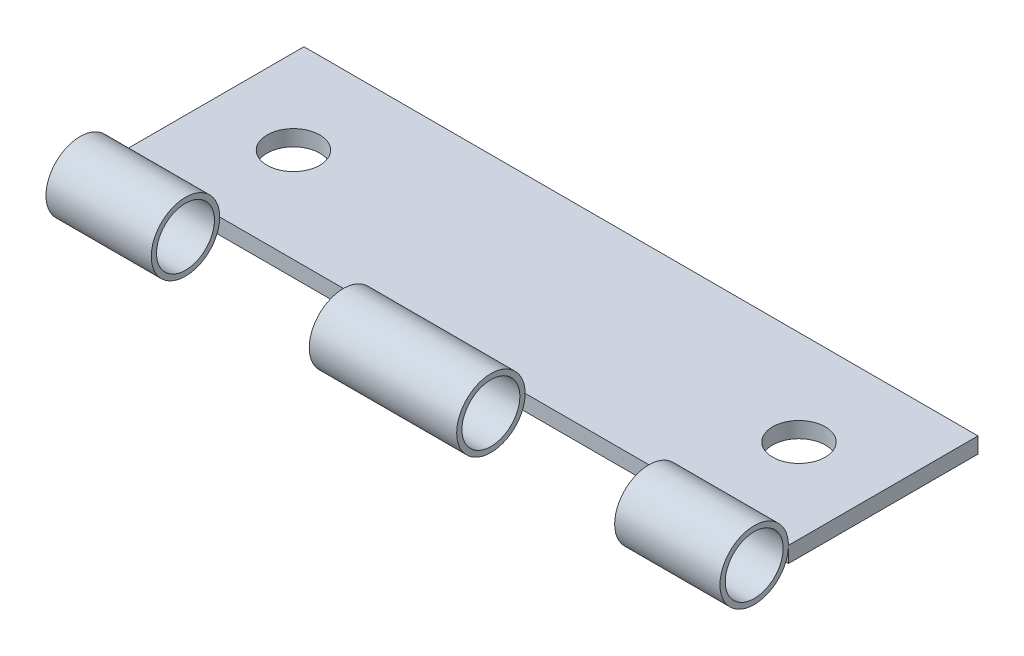
from build123d import *

# Parameters (mm, degrees)
SKETCH1_W               = 64
SKETCH1_H               = 18
BOSS_EXTRUDE1_DEPTH     = 1.5
SKETCH2_R               = 3.25
BOSS_EXTRUDE2_DEPTH     = 32
SKETCH3_R               = 2.5
CUT_EXTRUDE1_DEPTH      = 10
SKETCH4_W               = 15
SKETCH4_H               = 6.5
CUT_EXTRUDE4_DEPTH      = 44
CUT_EXTRUDE4_DEPTH_BACK = 44
SKETCH6_R               = 2.75
CUT_EXTRUDE5_DEPTH      = 64


with BuildPart() as part:
    # Sketch1 → Boss-Extrude1 (new body)
    with BuildSketch(Plane(origin=(0, 0, 0), x_dir=(1, 0, 0), z_dir=(0, 1, 0))):
        Rectangle(SKETCH1_W, SKETCH1_H)
    extrude(amount=BOSS_EXTRUDE1_DEPTH)

    # Sketch3 → Cut-Extrude1 (cut)
    with BuildSketch(Plane(origin=(0, 1.5, 0), x_dir=(1, 0, 0), z_dir=(0, 1, 0))):
        with Locations((-24, 0)):
            Circle(SKETCH3_R)
        with Locations((24, 0)):
            Circle(SKETCH3_R)
    extrude(amount=-CUT_EXTRUDE1_DEPTH, mode=Mode.SUBTRACT)


with BuildPart() as body_2:
    # Sketch2 → Boss-Extrude2 (new body, symmetric)
    with BuildSketch(Plane(origin=(0, 0, 0), x_dir=(0, 0, -1), z_dir=(1, 0, 0))):
        with Locations((-12.25, 1.5)):
            Circle(SKETCH2_R)
    extrude(amount=BOSS_EXTRUDE2_DEPTH, both=True)

    # Sketch4 → Cut-Extrude4 (cut, two sides)
    with BuildSketch(Plane(origin=(0, 0, 0), x_dir=(1, 0, 0), z_dir=(0, 1, 0))) as cut_extrude4_sk:
        with Locations((-14.5, -12.25)):
            Rectangle(SKETCH4_W, SKETCH4_H)
        with Locations((14.5, -12.25)):
            Rectangle(SKETCH4_W, SKETCH4_H)
    extrude(amount=CUT_EXTRUDE4_DEPTH, mode=Mode.SUBTRACT)
    extrude(cut_extrude4_sk.sketch, amount=-CUT_EXTRUDE4_DEPTH_BACK, mode=Mode.SUBTRACT)

    # Sketch6 → Cut-Extrude5 (cut)
    with BuildSketch(Plane(origin=(32, 0, 0), x_dir=(0, 0, -1), z_dir=(1, 0, 0))):
        with Locations((-12.25, 1.5)):
            Circle(SKETCH6_R)
    extrude(amount=-CUT_EXTRUDE5_DEPTH, mode=Mode.SUBTRACT)


solid = Compound([part.part, body_2.part])
